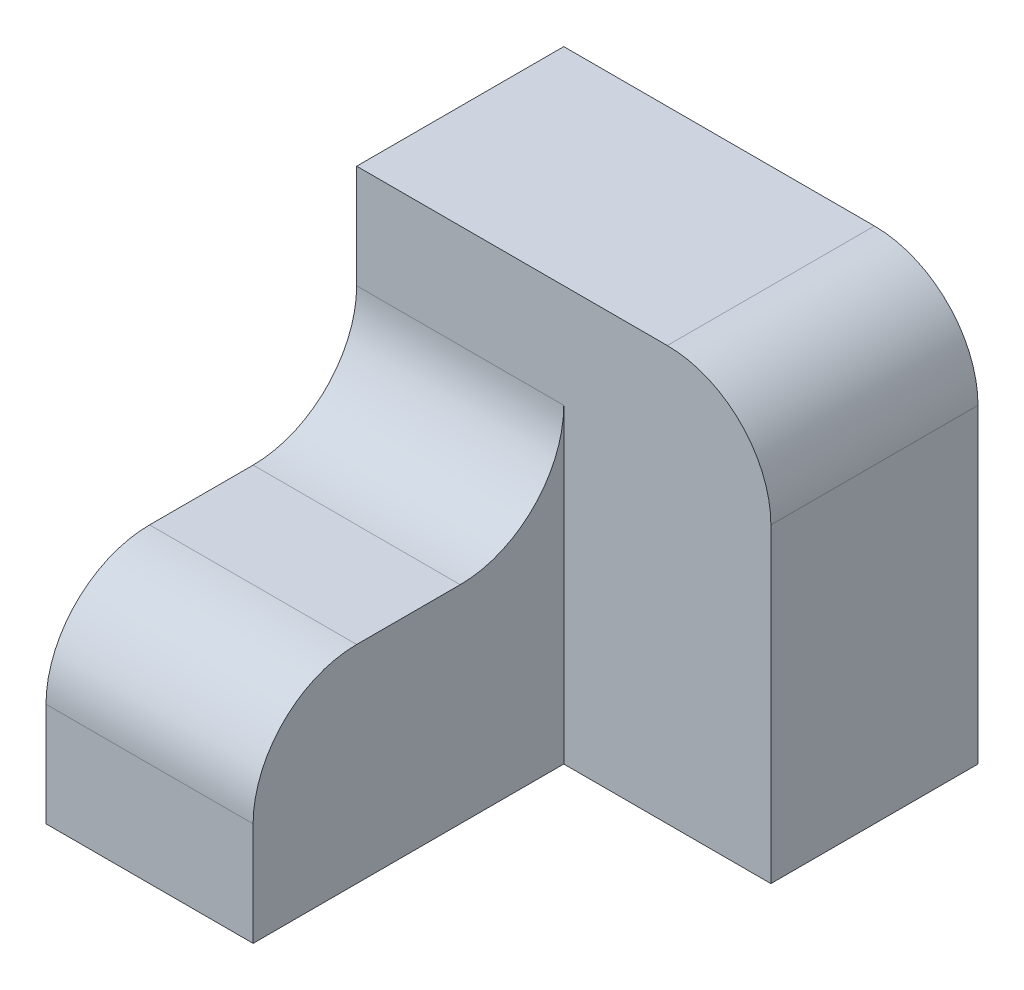
from build123d import *

# Parameters (mm, degrees)
SKETCH_1_W      = 20
SKETCH_1_H      = 30
EXTRUDE_1_DEPTH = 20
EXTRUDE_2_DEPTH = 40
FILLET_1_R      = 10


with BuildPart() as part:
    # 草圖1 → 填料-伸長1 (new body)
    with BuildSketch(Plane(origin=(0, 0, 0), x_dir=(1, 0, 0), z_dir=(0, 1, 0))):
        with Locations((10, 15)):
            Rectangle(SKETCH_1_W, SKETCH_1_H)
    extrude(amount=EXTRUDE_1_DEPTH)

    # 草圖1<3> → 填料-伸長2 (add)
    with BuildSketch(Plane(origin=(0, 0, 0), x_dir=(1, 0, 0), z_dir=(0, 1, 0))):
        Polygon((0, 50), (0, 30), (20, 30), (40, 30), (40, 50), align=None)
    extrude(amount=EXTRUDE_2_DEPTH)

    # 圓角1
    fillet_1_edges = [part.edges().sort_by_distance(p)[0] for p in [
        (10, 20, 0),
        (10, 20, -30),
        (40, 40, -40),
    ]]
    fillet(fillet_1_edges, radius=FILLET_1_R)


solid = part.part
